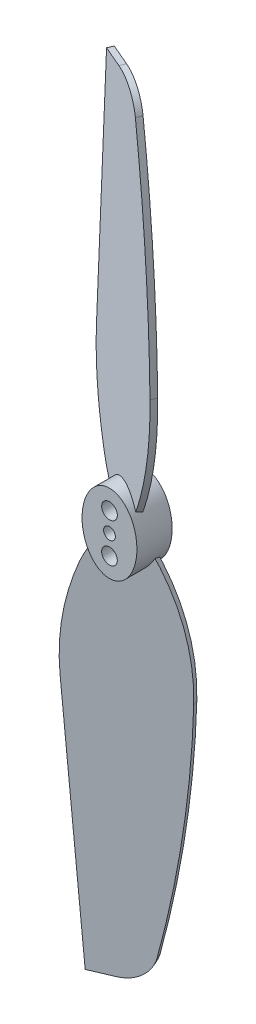
from build123d import *

# Parameters (mm, degrees)
BASE_CYL_DEPTH      = 4.5
PROPELLER_1_DEPTH   = 0.375
FLIP_ROTATION_ANGLE = 46.397181
SKETCH6_R           = 0.75
SKETCH6_R_2         = 1
HOLES_DEPTH         = 6.18946287


with BuildPart() as part:
    # Sketch1 → base cyl (new body)
    with BuildSketch(Plane(origin=(0, 0, 0), x_dir=(0, 1, 0), z_dir=(0, 0, 1))):
        with BuildLine():
            Line((0, 3.5), (0, -3.5))
            add(Edge.make_bspline(
                [(0, -3.5), (5, -3.5), (5, 0), (5, 3.5), (0, 3.5)],
                knots=[1.570796327, 1.570796327, 1.570796327, 3.141592654, 3.141592654, 4.71238898, 4.71238898, 4.71238898], degree=2, weights=[1, 0.707106781, 1, 0.707106781, 1]))
        make_face()
    extrude(amount=BASE_CYL_DEPTH)

    # mirror cyl: part across plane


with BuildPart() as body_2:
    # Sketch3 → propeller 1 (new body, symmetric)
    with BuildSketch(Plane(origin=(-0.814655172, 0, 1.900862069), x_dir=(0.91914503, 0, 0.393919299), z_dir=(-0.393919299, 0, 0.91914503))):
        with BuildLine():
            Line((-5.613681578, 18), (-3.169992707, 50))
            Line((-3.169992707, 50), (-0.169992707, 50))
            ThreePointArc((-0.169992707, 50), (2.38691804, 49.155307497), (3.830007293, 46.881809881))
            ThreePointArc((3.830007293, 46.881809881), (6.330689995, 32.529872056), (7.386318422, 18))
            ThreePointArc((7.386318422, 18), (6.084481394, 8.557505759), (1.886318422, 0))
            Line((1.886318422, 0), (-0.113681578, 0))
            ThreePointArc((-0.113681578, 0), (-2.2443271, 2.26430716), (-3.721730883, 5))
            ThreePointArc((-3.721730883, 5), (-5.38802994, 11.395167927), (-5.613681578, 18))
        make_face()
    extrude(amount=PROPELLER_1_DEPTH, both=True)


with BuildPart() as body_3:
    # mirror propeller: mirrored copy
    add(body_2.part.mirror(Plane(origin=(-3.5, 0, 4.5), x_dir=(0, 0, 1), z_dir=(0, 1, 0))))


with BuildPart() as body_3_1:
    # flip rotation: moved
    add(body_3.part.rotate(Axis((0.214116178, 0, 1.999751921), (0, 1, 0)), FLIP_ROTATION_ANGLE))


with BuildPart() as part_1:
    add(part.part)
    add(part.part.mirror(Plane(origin=(-3.5, 0, 4.5), x_dir=(0, 0, 1), z_dir=(0, 1, 0))))


with BuildPart() as holes_tool:
    # Sketch6 → holes (new body, through all)
    with BuildSketch(Plane.XY.offset(4.5)):
        Circle(SKETCH6_R)
        with Locations((0, 2.5)):
            Circle(SKETCH6_R_2)
        with Locations((0, -2.5)):
            Circle(SKETCH6_R_2)
    extrude(amount=-HOLES_DEPTH)


with BuildPart() as part_2:
    add(part_1.part)

    # holes: cut by holes_tool
    add(holes_tool.part, mode=Mode.SUBTRACT)


with BuildPart() as body_2_1:
    add(body_2.part)

    # holes: cut by holes_tool
    add(holes_tool.part, mode=Mode.SUBTRACT)


with BuildPart() as body_3_2:
    add(body_3_1.part)

    # holes: cut by holes_tool
    add(holes_tool.part, mode=Mode.SUBTRACT)


solid = Compound([part_2.part, body_2_1.part, body_3_2.part])
